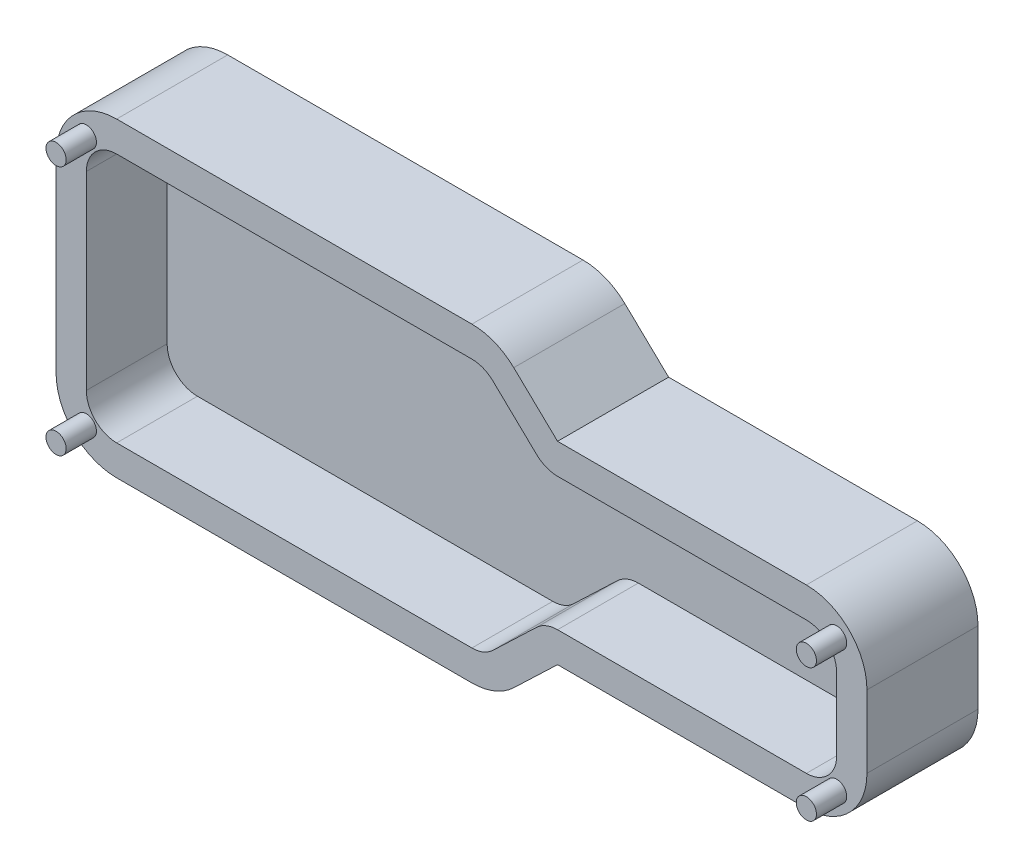
from build123d import *

# Parameters (mm, degrees)
SKETCH3_R                = 1
BOSS_EXTRUDE2_DEPTH      = 8
BOSS_EXTRUDE2_DEPTH_BACK = 3
BOSS_EXTRUDE3_DEPTH      = 3
SKETCH7_R                = 1
BOSS_EXTRUDE4_DEPTH      = 3
BOSS_EXTRUDE4_DEPTH_BACK = 11


with BuildPart() as part:
    # Sketch3 → Boss-Extrude2 (new, two sides)
    with BuildSketch(Plane.XY) as boss_extrude2_sk:
        with BuildLine():
            Line((-69.81, 20.47), (-34.625063383, 20.47))
            ThreePointArc((-34.625063383, 20.47), (-32.391172348, 20.03863815), (-30.478486436, 18.806576947))
            Line((-30.478486436, 18.806576947), (-26.141909489, 14.66))
            Line((-26.141909489, 14.66), (-1.5, 14.66))
            ThreePointArc((-1.5, 14.66), (2.742640687, 12.902640687), (4.5, 8.66))
            Line((4.5, 8.66), (4.5, 1.5))
            ThreePointArc((4.5, 1.5), (2.742640687, -2.742640687), (-1.5, -4.5))
            Line((-1.5, -4.5), (-26.141909489, -4.5))
            Line((-26.141909489, -4.5), (-30.478486436, -8.646576947))
            ThreePointArc((-30.478486436, -8.646576947), (-32.391172348, -9.87863815), (-34.625063383, -10.31))
            Line((-34.625063383, -10.31), (-69.81, -10.31))
            ThreePointArc((-69.81, -10.31), (-74.052640687, -8.552640687), (-75.81, -4.31))
            Line((-75.81, -4.31), (-75.81, 14.47))
            ThreePointArc((-75.81, 14.47), (-74.052640687, 18.712640687), (-69.81, 20.47))
        make_face()
        with Locations((-72.81, 17.47)):
            Circle(SKETCH3_R, mode=Mode.SUBTRACT)
        with Locations((-72.81, -7.31)):
            Circle(SKETCH3_R, mode=Mode.SUBTRACT)
        with Locations((1.5, -1.5)):
            Circle(SKETCH3_R, mode=Mode.SUBTRACT)
        with Locations((1.5, 11.66)):
            Circle(SKETCH3_R, mode=Mode.SUBTRACT)
        with BuildLine():
            Line((-69.81, 17.47), (-34.625063383, 17.47))
            ThreePointArc((-34.625063383, 17.47), (-33.508117866, 17.254319075), (-32.55177491, 16.638288474))
            Line((-32.55177491, 16.638288474), (-28.215197962, 12.491711526))
            ThreePointArc((-28.215197962, 12.491711526), (-27.258855006, 11.875680925), (-26.141909489, 11.66))
            Line((-26.141909489, 11.66), (-1.5, 11.66))
            ThreePointArc((-1.5, 11.66), (0.621320344, 10.781320344), (1.5, 8.66))
            Line((1.5, 8.66), (1.5, 1.5))
            ThreePointArc((1.5, 1.5), (0.621320344, -0.621320344), (-1.5, -1.5))
            Line((-1.5, -1.5), (-26.141909489, -1.5))
            ThreePointArc((-26.141909489, -1.5), (-27.258855006, -1.715680925), (-28.215197962, -2.331711526))
            Line((-28.215197962, -2.331711526), (-32.55177491, -6.478288474))
            ThreePointArc((-32.55177491, -6.478288474), (-33.508117866, -7.094319075), (-34.625063383, -7.31))
            Line((-34.625063383, -7.31), (-69.81, -7.31))
            ThreePointArc((-69.81, -7.31), (-71.931320344, -6.431320344), (-72.81, -4.31))
            Line((-72.81, -4.31), (-72.81, 14.47))
            ThreePointArc((-72.81, 14.47), (-71.931320344, 16.591320344), (-69.81, 17.47))
        make_face(mode=Mode.SUBTRACT)
    extrude(amount=BOSS_EXTRUDE2_DEPTH)
    extrude(boss_extrude2_sk.sketch, amount=-BOSS_EXTRUDE2_DEPTH_BACK)

    # Sketch5 → Boss-Extrude3 (add)
    with BuildSketch(Plane(origin=(0, 0, -3), x_dir=(-1, 0, 0), z_dir=(0, 0, -1))):
        with BuildLine():
            Line((72.81, 14.47), (72.81, -4.31))
            ThreePointArc((72.81, -4.31), (71.931320344, -6.431320344), (69.81, -7.31))
            Line((69.81, -7.31), (34.625063383, -7.31))
            ThreePointArc((34.625063383, -7.31), (33.508117866, -7.094319075), (32.55177491, -6.478288474))
            Line((32.55177491, -6.478288474), (28.215197962, -2.331711526))
            ThreePointArc((28.215197962, -2.331711526), (27.258855006, -1.715680925), (26.141909489, -1.5))
            Line((26.141909489, -1.5), (1.5, -1.5))
            ThreePointArc((1.5, -1.5), (-0.621320344, -0.621320344), (-1.5, 1.5))
            Line((-1.5, 1.5), (-1.5, 8.66))
            ThreePointArc((-1.5, 8.66), (-0.621320344, 10.781320344), (1.5, 11.66))
            Line((1.5, 11.66), (26.141909489, 11.66))
            ThreePointArc((26.141909489, 11.66), (27.258855006, 11.875680925), (28.215197962, 12.491711526))
            Line((28.215197962, 12.491711526), (32.55177491, 16.638288474))
            ThreePointArc((32.55177491, 16.638288474), (33.508117866, 17.254319075), (34.625063383, 17.47))
            Line((34.625063383, 17.47), (69.81, 17.47))
            ThreePointArc((69.81, 17.47), (71.931320344, 16.591320344), (72.81, 14.47))
        make_face()
    extrude(amount=-BOSS_EXTRUDE3_DEPTH)

    # Sketch7 → Boss-Extrude4 (add, two sides)
    with BuildSketch(Plane.XY.offset(8)) as boss_extrude4_sk:
        with Locations((-72.81, 17.47)):
            Circle(SKETCH7_R)
        with Locations((1.5, -1.5)):
            Circle(SKETCH7_R)
        with Locations((1.5, 11.66)):
            Circle(SKETCH7_R)
        with Locations((-72.81, -7.31)):
            Circle(SKETCH7_R)
    extrude(amount=BOSS_EXTRUDE4_DEPTH)
    extrude(boss_extrude4_sk.sketch, amount=-BOSS_EXTRUDE4_DEPTH_BACK)


solid = part.part
